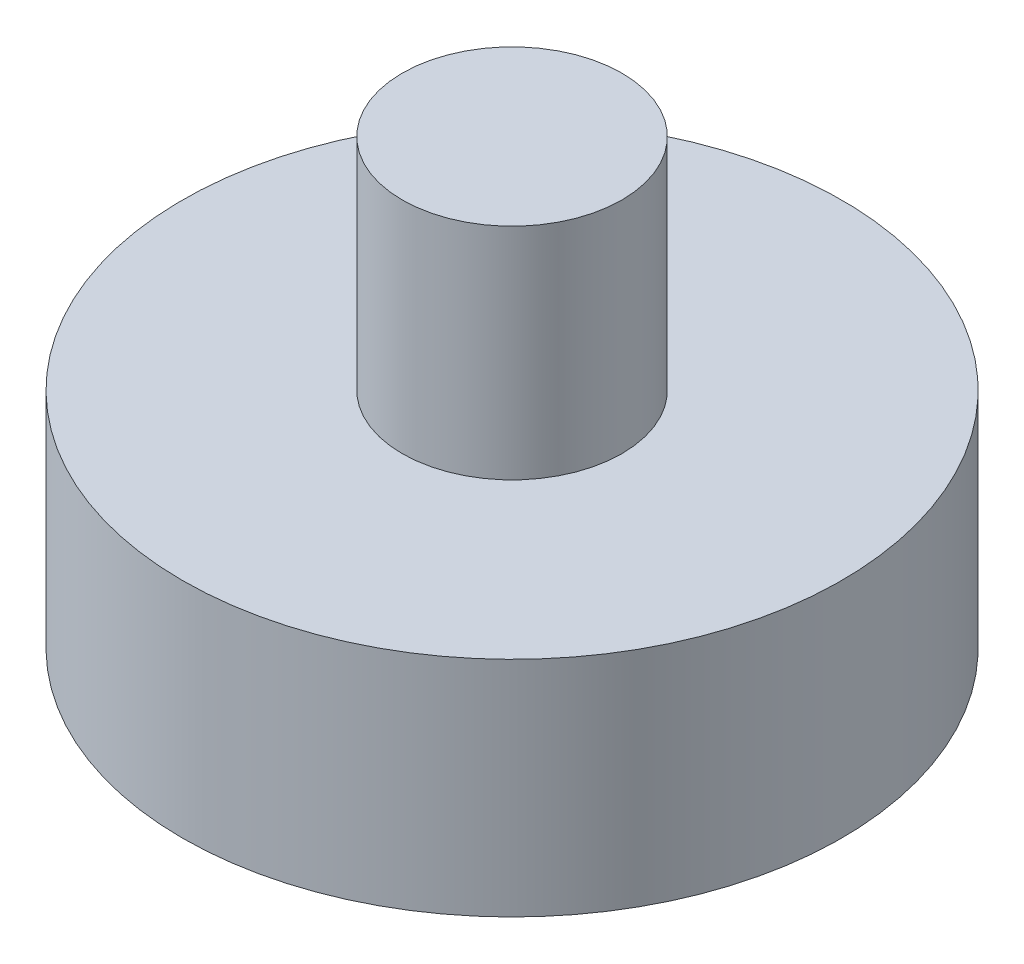
from build123d import *

# Parameters (mm, degrees)
SKETCH1_LINK0_R     = 60
BOSS_EXTRUDE1_DEPTH = 20.3125
SKETCH2_LINK0_R     = 20
BOSS_EXTRUDE2_DEPTH = 40


with BuildPart() as part:
    # sketch1_link0 → Boss-Extrude1 (new body, symmetric)
    with BuildSketch(Plane(origin=(0, 0, 0), x_dir=(1, 0, 0), z_dir=(0, 1, 0))):
        Circle(SKETCH1_LINK0_R)
    extrude(amount=BOSS_EXTRUDE1_DEPTH, both=True)

    # sketch2_link0 → Boss-Extrude2 (add)
    with BuildSketch(Plane(origin=(0, 20.3125, 0), x_dir=(1, 0, 0), z_dir=(0, 1, 0))):
        Circle(SKETCH2_LINK0_R)
    extrude(amount=BOSS_EXTRUDE2_DEPTH)


solid = part.part
